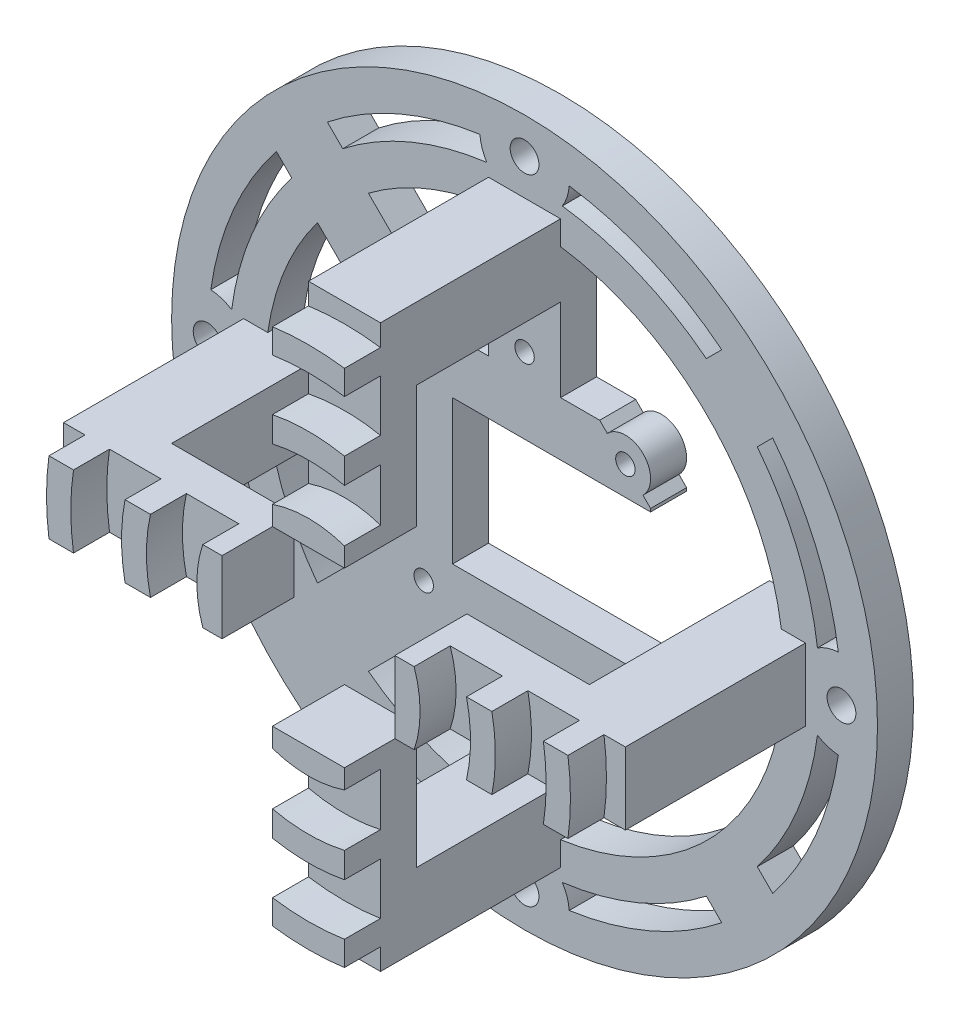
from build123d import *

# Parameters (mm, degrees)
SKETCH1_R            = 49
BOSS_EXTRUDE1_DEPTH  = 5
CUT_EXTRUDE11_DEPTH  = 6
SKETCH24_R           = 1.35
CUT_EXTRUDE12_DEPTH  = 6
SKETCH25_R           = 2
CUT_EXTRUDE13_DEPTH  = 6
CIRPATTERN6_COUNT    = 4
SKETCH26_W           = 10
SKETCH26_H           = 10
BOSS_EXTRUDE23_DEPTH = 20
CIRPATTERN7_COUNT    = 4
SKETCH28_W           = 10
SKETCH28_H           = 27
BOSS_EXTRUDE25_DEPTH = 5
CIRPATTERN9_COUNT    = 4
BOSS_EXTRUDE26_DEPTH = 5
CIRPATTERN10_COUNT   = 4
SKETCH30_R           = 41
SKETCH30_R_2         = 36
BOSS_EXTRUDE27_DEPTH = 5
CUT_EXTRUDE14_DEPTH  = 5
SKETCH32_W           = 20
SKETCH32_H           = 20
SKETCH32_W_2         = 7.5
CUT_EXTRUDE15_DEPTH  = 5
SKETCH34_R           = 1.35
CUT_EXTRUDE16_DEPTH  = 5
CIRPATTERN11_COUNT   = 2
CIRPATTERN11_ANGLE   = 90


with BuildPart() as part:
    # Sketch1 → Boss-Extrude1 (new body)
    with BuildSketch(Plane.XY):
        Circle(SKETCH1_R)
    extrude(amount=BOSS_EXTRUDE1_DEPTH)

    # Sketch23 → Cut-Extrude11 (cut, through all)
    with BuildSketch(Plane.XY.offset(5)):
        with BuildLine():
            ThreePointArc((-40.313027208, 5), (-41.852174996, 5.829289504), (-43.56143445, 6.196888625))
            ThreePointArc((-43.56143445, 6.196888625), (-40.415985736, 17.393909768), (-34.446696938, 27.375629126))
            Line((-34.446696938, 27.375629126), (-17.5, 10.428932188))
            Line((-17.5, 10.428932188), (-17.5, 5))
            Line((-17.5, 5), (-40.313027208, 5))
        make_face()
        with BuildLine():
            ThreePointArc((-43.56143445, -6.196888625), (-41.852174996, -5.829289504), (-40.313027208, -5))
            Line((-40.313027208, -5), (-17.5, -5))
            Line((-17.5, -5), (-17.5, -10.428932188))
            Line((-17.5, -10.428932188), (-34.446696938, -27.375629126))
            ThreePointArc((-34.446696938, -27.375629126), (-40.415985736, -17.393909768), (-43.56143445, -6.196888625))
        make_face()
        with BuildLine():
            ThreePointArc((-5, -40.313027208), (-5.829289504, -41.852174996), (-6.196888625, -43.56143445))
            ThreePointArc((-6.196888625, -43.56143445), (-17.393909768, -40.415985736), (-27.375629126, -34.446696938))
            Line((-27.375629126, -34.446696938), (-10.428932188, -17.5))
            Line((-10.428932188, -17.5), (-5, -17.5))
            Line((-5, -17.5), (-5, -40.313027208))
        make_face()
        with BuildLine():
            ThreePointArc((6.196888625, -43.56143445), (5.829289504, -41.852174996), (5, -40.313027208))
            Line((5, -40.313027208), (5, -17.5))
            Line((5, -17.5), (10.428932188, -17.5))
            Line((10.428932188, -17.5), (27.375629126, -34.446696938))
            ThreePointArc((27.375629126, -34.446696938), (17.393909768, -40.415985736), (6.196888625, -43.56143445))
        make_face()
        with BuildLine():
            ThreePointArc((43.56143445, 6.196888625), (41.852174996, 5.829289504), (40.313027208, 5))
            Line((40.313027208, 5), (17.5, 5))
            Line((17.5, 5), (17.5, 10.428932188))
            Line((17.5, 10.428932188), (34.446696938, 27.375629126))
            ThreePointArc((34.446696938, 27.375629126), (40.415985736, 17.393909768), (43.56143445, 6.196888625))
        make_face()
        with BuildLine():
            Line((10.428932188, 17.5), (27.375629126, 34.446696938))
            ThreePointArc((27.375629126, 34.446696938), (17.393909768, 40.415985736), (6.196888625, 43.56143445))
            ThreePointArc((6.196888625, 43.56143445), (5.829289504, 41.852174996), (5, 40.313027208))
            Line((5, 40.313027208), (5, 17.5))
            Line((5, 17.5), (10.428932188, 17.5))
        make_face()
        with BuildLine():
            ThreePointArc((-6.196888625, 43.56143445), (-5.829289504, 41.852174996), (-5, 40.313027208))
            Line((-5, 40.313027208), (-5, 17.5))
            Line((-5, 17.5), (-10.428932188, 17.5))
            Line((-10.428932188, 17.5), (-27.375629126, 34.446696938))
            ThreePointArc((-27.375629126, 34.446696938), (-17.393909768, 40.415985736), (-6.196888625, 43.56143445))
        make_face()
        with BuildLine():
            Line((17.5, -10.428932188), (34.446696938, -27.375629126))
            ThreePointArc((34.446696938, -27.375629126), (40.415985736, -17.393909768), (43.56143445, -6.196888625))
            ThreePointArc((43.56143445, -6.196888625), (41.852174996, -5.829289504), (40.313027208, -5))
            Line((40.313027208, -5), (17.5, -5))
            Line((17.5, -5), (17.5, -10.428932188))
        make_face()
    extrude(amount=-CUT_EXTRUDE11_DEPTH, mode=Mode.SUBTRACT)

    # Sketch24 → Cut-Extrude12 (cut, through all)
    with BuildSketch(Plane.XY.offset(5)):
        with Locations((-14, 14)):
            Circle(SKETCH24_R)
        with Locations((14, 14)):
            Circle(SKETCH24_R)
        with Locations((14, -14)):
            Circle(SKETCH24_R)
        with Locations((-14, -14)):
            Circle(SKETCH24_R)
    extrude(amount=-CUT_EXTRUDE12_DEPTH, mode=Mode.SUBTRACT)

    # Sketch25 → Cut-Extrude13 (cut, through all)
    with BuildSketch(Plane.XY.offset(5)):
        with Locations((0, 44)):
            Circle(SKETCH25_R)
    cut_extrude13 = extrude(amount=-CUT_EXTRUDE13_DEPTH, mode=Mode.SUBTRACT)

    # CirPattern6: Cut-Extrude13 ×4 about axis
    cirpattern6_axis = Axis((0, 0, 0), (0, 0, 1))
    for i in range(1, CIRPATTERN6_COUNT):
        add(cut_extrude13.rotate(cirpattern6_axis, i * 360 / CIRPATTERN6_COUNT), mode=Mode.SUBTRACT)

    # Sketch26 → Boss-Extrude23 (add)
    with BuildSketch(Plane.XY.offset(5)):
        with Locations((0, 34)):
            Rectangle(SKETCH26_W, SKETCH26_H)
    boss_extrude23 = extrude(amount=BOSS_EXTRUDE23_DEPTH)

    # CirPattern7: Boss-Extrude23 ×4 about axis
    cirpattern7_axis = Axis((0, 0, 0), (0, 0, 1))
    for i in range(1, CIRPATTERN7_COUNT):
        add(boss_extrude23.rotate(cirpattern7_axis, i * 360 / CIRPATTERN7_COUNT))

    # Sketch28 → Boss-Extrude25 (add)
    with BuildSketch(Plane.XY.offset(25)):
        with Locations((0, 25.5)):
            Rectangle(SKETCH28_W, SKETCH28_H)
    boss_extrude25 = extrude(amount=BOSS_EXTRUDE25_DEPTH)

    # CirPattern9: Boss-Extrude25 ×4 about axis
    cirpattern9_axis = Axis((0, 0, 0), (0, 0, 1))
    for i in range(1, CIRPATTERN9_COUNT):
        add(boss_extrude25.rotate(cirpattern9_axis, i * 360 / CIRPATTERN9_COUNT))

    # Sketch29 → Boss-Extrude26 (add)
    with BuildSketch(Plane.XY.offset(30)):
        with BuildLine():
            ThreePointArc((-5, 32.619012861), (0, 33), (5, 32.619012861))
            Line((5, 32.619012861), (5, 36.024670713))
            ThreePointArc((5, 36.024670713), (0, 36.37), (-5, 36.024670713))
            Line((-5, 36.024670713), (-5, 32.619012861))
        make_face()
        with BuildLine():
            ThreePointArc((-5, 21.937410968), (0, 22.5), (5, 21.937410968))
            Line((5, 21.937410968), (5, 25.463748742))
            ThreePointArc((5, 25.463748742), (0, 25.95), (-5, 25.463748742))
            Line((-5, 25.463748742), (-5, 21.937410968))
        make_face()
        with BuildLine():
            Line((-5, 12), (5, 12))
            Line((5, 12), (5, 14.671400751))
            ThreePointArc((5, 14.671400751), (0, 15.5), (-5, 14.671400751))
            Line((-5, 14.671400751), (-5, 12))
        make_face()
    boss_extrude26 = extrude(amount=BOSS_EXTRUDE26_DEPTH)

    # CirPattern10: Boss-Extrude26 ×4 about axis
    cirpattern10_axis = Axis((0, 0, 0), (0, 0, 1))
    for i in range(1, CIRPATTERN10_COUNT):
        add(boss_extrude26.rotate(cirpattern10_axis, i * 360 / CIRPATTERN10_COUNT))

    # Sketch30 → Boss-Extrude27 (add)
    with BuildSketch(Plane(origin=(0, 0, 0), x_dir=(-1, 0, 0), z_dir=(0, 0, -1))):
        Circle(SKETCH30_R)
        Circle(SKETCH30_R_2, mode=Mode.SUBTRACT)
    extrude(amount=-BOSS_EXTRUDE27_DEPTH)

    # Sketch31 → Cut-Extrude14 (cut)
    with BuildSketch(Plane(origin=(0, 0, 0), x_dir=(-1, 0, 0), z_dir=(0, 0, -1))):
        with BuildLine():
            Line((-5, 35.65108694), (-5, 17.5))
            Line((-5, 17.5), (-10.428932188, 17.5))
            Line((-10.428932188, 17.5), (-11.489847469, 16.43908472))
            ThreePointArc((-11.489847469, 16.43908472), (-16.474873734, 16.474873734), (-16.43908472, 11.489847469))
            Line((-16.43908472, 11.489847469), (-17.5, 10.428932188))
            Line((-17.5, 10.428932188), (-17.5, -10.428932188))
            Line((-17.5, -10.428932188), (-16.449876269, -11.500378775))
            ThreePointArc((-16.449876269, -11.500378775), (-16.474873734, -16.474873734), (-11.500378775, -16.449876269))
            Line((-11.500378775, -16.449876269), (-10.428932188, -17.5))
            Line((-10.428932188, -17.5), (-5, -17.5))
            Line((-5, -17.5), (-5, -35.65108694))
            ThreePointArc((-5, -35.65108694), (-25.455844123, -25.455844123), (-35.65108694, -5))
            Line((-35.65108694, -5), (-29.00108694, -5))
            Line((-29.00108694, -5), (-29.00108694, 5))
            Line((-29.00108694, 5), (-35.65108694, 5))
            ThreePointArc((-35.65108694, 5), (-25.455844123, 25.455844123), (-5, 35.65108694))
        make_face()
    extrude(amount=-CUT_EXTRUDE14_DEPTH, mode=Mode.SUBTRACT)

    # Sketch32 → Cut-Extrude15 (cut)
    with BuildSketch(Plane(origin=(0, 0, 0), x_dir=(-1, 0, 0), z_dir=(0, 0, -1))):
        Rectangle(SKETCH32_W, SKETCH32_H)
        with Locations((-13.75, 0)):
            Rectangle(SKETCH32_W_2, SKETCH32_H)
    extrude(amount=-CUT_EXTRUDE15_DEPTH, mode=Mode.SUBTRACT)

    # Sketch34 → Cut-Extrude16 (cut)
    with BuildSketch(Plane(origin=(0, 0, 0), x_dir=(-1, 0, 0), z_dir=(0, 0, -1))):
        with Locations((0, 20.5)):
            Circle(SKETCH34_R)
        with Locations((0, 35.5)):
            Circle(SKETCH34_R)
    cut_extrude16 = extrude(amount=-CUT_EXTRUDE16_DEPTH, mode=Mode.SUBTRACT)

    # CirPattern11: Cut-Extrude16 ×2 about axis
    cirpattern11_axis = Axis((0, 0, 0), (0, 0, 1))
    for i in range(1, CIRPATTERN11_COUNT):
        add(cut_extrude16.rotate(cirpattern11_axis, i * CIRPATTERN11_ANGLE / (CIRPATTERN11_COUNT - 1)), mode=Mode.SUBTRACT)


solid = part.part
